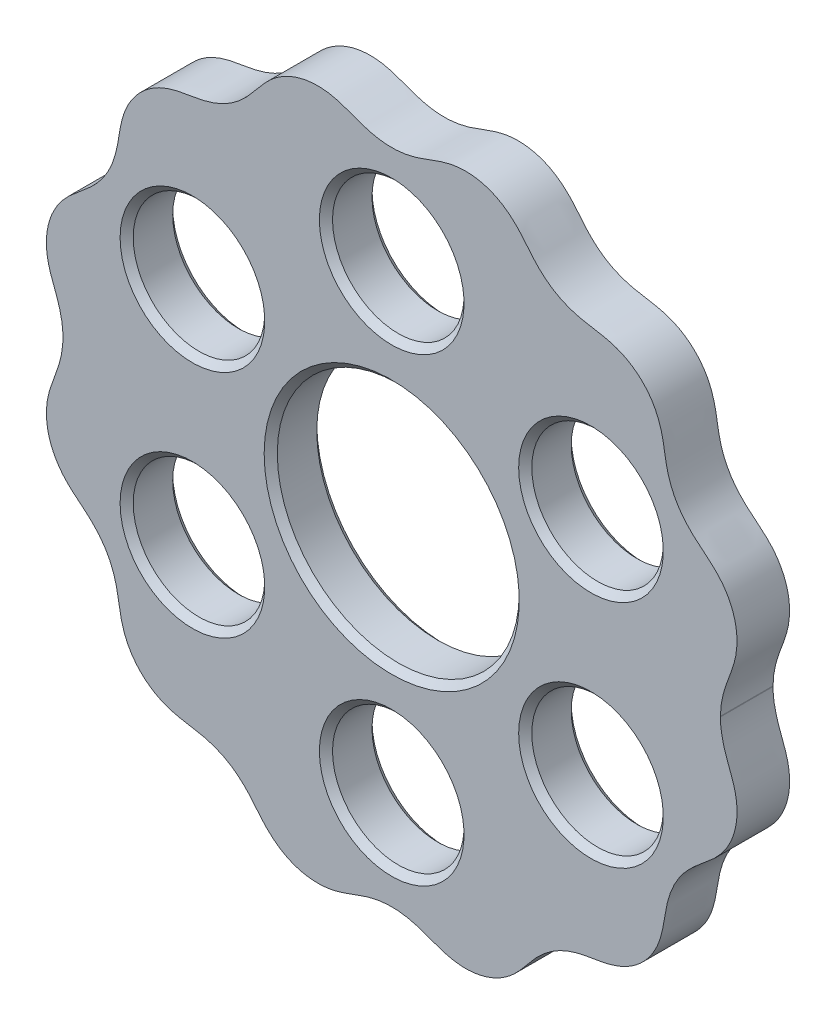
from build123d import *

# Parameters (mm, degrees)
SKETCH3_R           = 9.2
SKETCH3_R_2         = 5
BOSS_EXTRUDE2_DEPTH = 4
CHAMFER1_SIZE       = 0.5


with BuildPart() as part:
    # Sketch3 → Boss-Extrude2 (new body)
    with BuildSketch(Plane.XY):
        with BuildLine():
            add(Edge.make_bspline(
                [(25, 0), (25, -0.028419379), (25.000492821, -0.085240091), (25.002710517, -0.186096381), (25.008616202, -0.331732724), (25.017454216, -0.471095426), (25.029199756, -0.604110594), (25.043819456, -0.735775062), (25.0612711, -0.868216065), (25.086561311, -1.034185241), (25.122348392, -1.232409452), (25.171720804, -1.461619521), (25.23785416, -1.72161835), (25.33146082, -2.043525868), (25.437671669, -2.361532194), (25.552791346, -2.676356937), (25.69530689, -3.052450734), (25.837320412, -3.428807717), (26.007461604, -3.919608843), (26.169082038, -4.536352918), (26.29301302, -5.400577617), (26.248865742, -6.509268079), (25.900590468, -7.758927573), (25.250933039, -8.824024045), (24.559448754, -9.548775191), (23.872924134, -10.132867754), (23.242034799, -10.633504856), (22.540451444, -11.262027255), (21.859772382, -12.093532725), (21.337087227, -13.027141562), (20.986474338, -14.032216693), (20.783152218, -15.069054613), (20.629229677, -16.210615672), (20.295790024, -17.423577203), (19.620081418, -18.614367157), (18.57817853, -19.648167397), (17.377311503, -20.316253266), (16.151486918, -20.639994045), (14.739949908, -20.826544524), (13.439402762, -21.1258531), (12.23711891, -21.731124361), (11.217263285, -22.586282659), (10.510510486, -23.382376891), (9.803864636, -24.301158332), (8.912502074, -25.202295013), (7.731407454, -25.911659846), (6.309337856, -26.299864083), (4.931582798, -26.288472232), (3.706115601, -25.964583322), (2.633674004, -25.522967435), (1.62667227, -25.181750578), (0.581426656, -24.989102643), (-0.478930933, -24.980713481), (-1.520966388, -25.154635937), (-2.520449471, -25.479461333), (-3.419229104, -25.84785235), (-4.274357012, -26.11935553), (-5.084141891, -26.255225085), (-5.827195666, -26.277840049), (-6.751118437, -26.176673588), (-7.819413481, -25.850368791), (-8.864535557, -25.241992085), (-9.774472842, -24.337578456), (-10.489042176, -23.409443312), (-11.198070814, -22.604475083), (-12.019349647, -21.910802096), (-12.950687048, -21.371323607), (-13.961150534, -21.004447957), (-15.012542859, -20.790681073), (-16.17349347, -20.636604415), (-17.412795128, -20.30409628), (-18.621589199, -19.617234196), (-19.535225069, -18.69087907), (-20.109505434, -17.744490957), (-20.468260184, -16.811352879), (-20.669325741, -15.929542243), (-20.800368009, -14.951283195), (-21.021499046, -13.897450049), (-21.399469544, -12.891789727), (-21.945671579, -11.971536034), (-22.639598338, -11.164500934), (-23.435367487, -10.469229858), (-24.347111984, -9.765350187), (-25.232158972, -8.871517572), (-25.925709908, -7.694669196), (-26.301679816, -6.282910402), (-26.285367064, -4.916976266), (-25.96232166, -3.701401982), (-25.524214021, -2.636206013), (-25.184526072, -1.63546138), (-24.98964456, -0.589100982), (-24.979676648, 0.481005828), (-25.157831343, 1.540454587), (-25.495205931, 2.562927815), (-25.870736407, 3.4757204), (-26.135455064, 4.34059116), (-26.288515222, 5.328583568), (-26.261093111, 6.43001327), (-25.933564455, 7.678441647), (-25.237701394, 8.866637346), (-24.34504384, 9.767557339), (-23.427022399, 10.47557852), (-22.62699323, 11.1763696), (-21.936896568, 11.984292454), (-21.397747575, 12.897748952), (-21.026718925, 13.886522177), (-20.806135146, 14.914602211), (-20.653045268, 16.060286336), (-20.395622874, 17.11611043), (-19.95690194, 18.028441349), (-19.300149626, 18.928757994), (-18.483671803, 19.692277913), (-17.435839429, 20.294614033), (-16.197622229, 20.632400397), (-15.036829757, 20.787344769), (-13.984887122, 20.997904882), (-12.973147938, 21.361026229), (-12.039474616, 21.896555136), (-11.215678135, 22.58716662), (-10.504008287, 23.390162439), (-9.790282182, 24.318640694), (-8.884052218, 25.226941722), (-7.685868846, 25.932204762), (-6.427337904, 26.262197332), (-5.32062142, 26.288060185), (-4.332905845, 26.133623194), (-3.468339345, 25.867884001), (-2.55560208, 25.492296977), (-1.532755887, 25.155882506), (-0.473083435, 24.979033961), (0.597006536, 24.990441303), (1.643127458, 25.186582226), (2.643510183, 25.527172752), (3.708827205, 25.965063812), (4.924909383, 26.286396603), (6.29085556, 26.300692327), (7.702048601, 25.922603812), (8.877880267, 25.227310889), (9.770417048, 24.341030317), (10.474070774, 23.429151565), (11.170105737, 22.633979321), (11.977973527, 21.941022037), (12.898969216, 21.396054985), (13.905080963, 21.019330701), (14.959093015, 20.79921578), (15.93734026, 20.668117182), (16.818953838, 20.466007301), (17.751576334, 20.105941467), (18.697120313, 19.53023506), (19.622089623, 18.615234931), (20.307180817, 17.405403853), (20.637904711, 16.165690953), (20.791787115, 15.004742729), (21.00656033, 13.953487), (21.374668771, 12.943487437), (21.915401419, 12.012841988), (22.610070929, 11.192473379), (23.415648604, 10.48411951), (24.343684699, 9.769551905), (25.246796647, 8.857951736), (25.940942688, 7.662077141), (26.262511444, 6.413848041), (26.28479299, 5.412288327), (26.191439435, 4.704296235), (26.088108997, 4.226630913), (25.967232391, 3.802316147), (25.80790495, 3.345695262), (25.619629464, 2.855327013), (25.458833672, 2.424502992), (25.333860765, 2.050706314), (25.241721849, 1.735435761), (25.176361339, 1.480873774), (25.120257899, 1.224415288), (25.074119122, 0.965148365), (25.038505918, 0.70465122), (25.016960864, 0.482504301), (25.005267885, 0.264321243), (25.00135895, 0.133217809), (25.000430803, 0.077544036), (25.000203175, 0.049701947)],
                knots=[0.076056741, 0.076056741, 0.076056741, 0.076056741, 0.076056741, 0.076716626, 0.077376511, 0.078036395, 0.07869628, 0.079356165, 0.080016049, 0.080675934, 0.081335819, 0.082655588, 0.083975357, 0.085295127, 0.086614896, 0.089254435, 0.090574204, 0.091893973, 0.094533512, 0.097173051, 0.100798473, 0.104423896, 0.11167474, 0.118848356, 0.126021971, 0.128665019, 0.131308067, 0.136594162, 0.141880258, 0.147166354, 0.152357566, 0.157548778, 0.16273999, 0.167931202, 0.175042017, 0.182152833, 0.189326507, 0.196500181, 0.201723091, 0.206946, 0.217391818, 0.222614771, 0.227837725, 0.233060678, 0.238283631, 0.245457287, 0.252630943, 0.259804707, 0.266978471, 0.272201179, 0.277423888, 0.282646597, 0.287869306, 0.293029544, 0.298189783, 0.303350022, 0.308510261, 0.312159961, 0.315809662, 0.319459363, 0.323109064, 0.330383447, 0.337657831, 0.342925117, 0.348192403, 0.353459689, 0.358726976, 0.363994339, 0.369261702, 0.374529065, 0.379796429, 0.387070764, 0.394345099, 0.401518721, 0.405105533, 0.408692344, 0.413978427, 0.419264509, 0.424550592, 0.429836675, 0.435027902, 0.440219129, 0.445410356, 0.450601583, 0.457712386, 0.464823188, 0.471933966, 0.479044743, 0.484236012, 0.489427281, 0.49461855, 0.499809819, 0.505095864, 0.510381909, 0.515667954, 0.520953999, 0.524540818, 0.528127637, 0.535301275, 0.542475056, 0.549648837, 0.554871514, 0.56009419, 0.565316866, 0.570539542, 0.575699809, 0.580860077, 0.586020345, 0.591180612, 0.598480006, 0.602129703, 0.605779399, 0.613053806, 0.620328213, 0.625595461, 0.630862709, 0.636129958, 0.641397206, 0.646664608, 0.651932009, 0.65719941, 0.662466812, 0.669741122, 0.677015431, 0.684189061, 0.687775877, 0.691362692, 0.696648757, 0.701934822, 0.707220888, 0.712506953, 0.7176982, 0.722889446, 0.728080693, 0.73327194, 0.740382729, 0.747493519, 0.754604309, 0.761715099, 0.766906345, 0.772097591, 0.777288837, 0.782480083, 0.787766149, 0.793052215, 0.798338281, 0.803624347, 0.807211162, 0.810797977, 0.817971607, 0.825245917, 0.832520228, 0.837787628, 0.843055028, 0.848322428, 0.853589828, 0.858857078, 0.864124328, 0.869391577, 0.874658827, 0.881933233, 0.889207639, 0.896231602, 0.899743584, 0.901499575, 0.903255566, 0.905841573, 0.908427581, 0.911013588, 0.913599595, 0.914892599, 0.916185603, 0.917478607, 0.91877161, 0.920064614, 0.921357618, 0.922650621, 0.923297123, 0.923943625, 0.923943625, 0.923943625, 0.923943625, 0.923943625], degree=4))
            Line((25.000203175, 0.049701947), (25, 0))
        make_face()
        Circle(SKETCH3_R, mode=Mode.SUBTRACT)
        with Locations((0, 17.5)):
            Circle(SKETCH3_R_2, mode=Mode.SUBTRACT)
        with Locations((15.155444566, 8.75)):
            Circle(SKETCH3_R_2, mode=Mode.SUBTRACT)
        with Locations((15.155444566, -8.75)):
            Circle(SKETCH3_R_2, mode=Mode.SUBTRACT)
        with Locations((0, -17.5)):
            Circle(SKETCH3_R_2, mode=Mode.SUBTRACT)
        with Locations((-15.155444566, -8.75)):
            Circle(SKETCH3_R_2, mode=Mode.SUBTRACT)
        with Locations((-15.155444566, 8.75)):
            Circle(SKETCH3_R_2, mode=Mode.SUBTRACT)
    extrude(amount=BOSS_EXTRUDE2_DEPTH)

    # Chamfer1
    chamfer1_edges = [part.edges().sort_by_distance(p)[0] for p in [
        (-5, 17.5, 0),
        (-5, 17.5, 4),
        (-5, -17.5, 0),
        (-5, -17.5, 4),
        (10.155444566, 8.75, 0),
        (10.155444566, 8.75, 4),
        (10.155444566, -8.75, 0),
        (10.155444566, -8.75, 4),
        (-20.155444566, -8.75, 0),
        (-20.155444566, -8.75, 4),
        (-20.155444566, 8.75, 0),
        (-20.155444566, 8.75, 4),
        (-9.2, 0, 0),
        (-9.2, 0, 4),
    ]]
    chamfer(chamfer1_edges, length=CHAMFER1_SIZE)


solid = part.part
